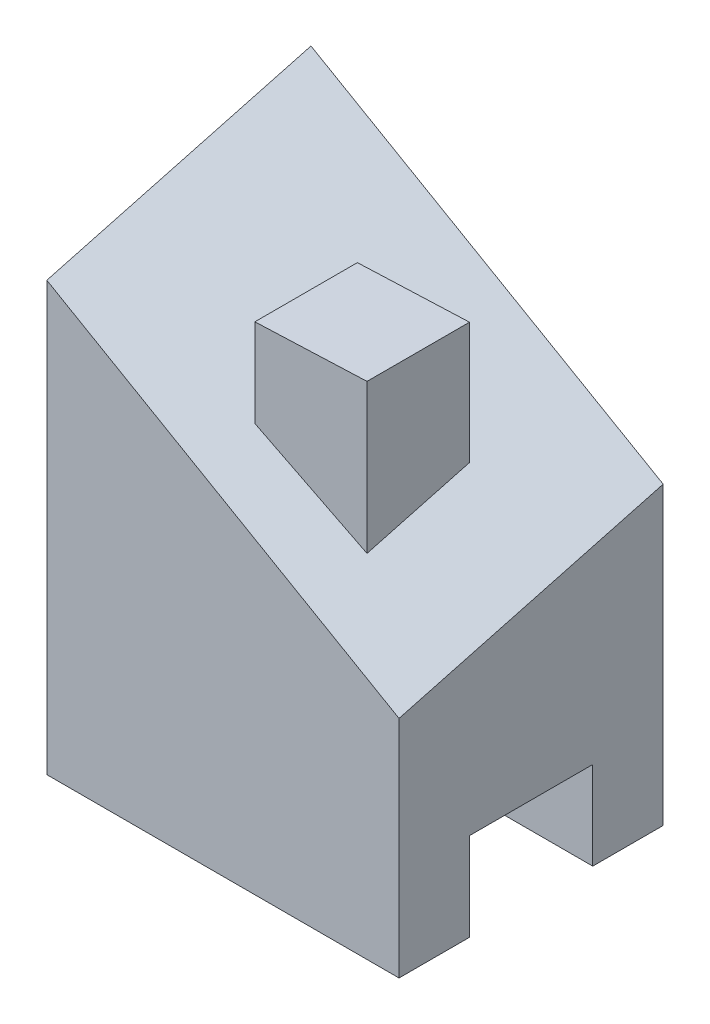
from build123d import *

# Parameters (mm, degrees)
SKETCH1_W                = 60
SKETCH1_H                = 45
BOSS_EXTRUDE1_DEPTH      = 85
SKETCH2_W                = 21
SKETCH2_H                = 15
CUT_EXTRUDE1_DEPTH       = 85
CUT_EXTRUDE7_DEPTH       = 53
CUT_EXTRUDE9_DEPTH       = 42
CUT_EXTRUDE10_DEPTH      = 42
BOSS_EXTRUDE6_DEPTH      = 15
BOSS_EXTRUDE6_DEPTH_BACK = 15


with BuildPart() as part:
    # Sketch1 → Boss-Extrude1 (new body)
    with BuildSketch(Plane(origin=(0, 0, 0), x_dir=(1, 0, 0), z_dir=(0, 1, 0))):
        with Locations((30, 22.5)):
            Rectangle(SKETCH1_W, SKETCH1_H)
    extrude(amount=BOSS_EXTRUDE1_DEPTH)

    # Sketch2 → Cut-Extrude1 (cut)
    with BuildSketch(Plane(origin=(60, 0, 0), x_dir=(0, 0, -1), z_dir=(1, 0, 0))):
        with Locations((22.5, 7.5)):
            Rectangle(SKETCH2_W, SKETCH2_H)
    extrude(amount=-CUT_EXTRUDE1_DEPTH, mode=Mode.SUBTRACT)

    # Sketch10 → Cut-Extrude7 (cut)
    with BuildSketch(Plane.XY):
        Polygon((0, 85), (60, 50.358983849), (60, 85), align=None)
    extrude(amount=-CUT_EXTRUDE7_DEPTH, mode=Mode.SUBTRACT)

    # Sketch16 → Cut-Extrude9 (cut)
    with BuildSketch(Plane.ZY):
        Polygon((-45, 85), (0, 72.942286341), (0, 85), align=None)
    extrude(amount=-CUT_EXTRUDE9_DEPTH, mode=Mode.SUBTRACT)

    # Sketch17 → Cut-Extrude10 (cut)
    with BuildSketch(Plane(origin=(29.971067136, 51.911411037, 13.909620665), x_dir=(0.8733693623277136, -0.47046235880286186, -0.12606000911046442), z_dir=(0.48705847384814394, 0.843610022961955, 0.22604462437945042))):
        Polygon((34.382855821, 56.500526295), (34.382855821, 9.913098177), (-34.316600088, 18.878852898), (-34.316600088, 65.466281017), align=None)
    extrude(amount=CUT_EXTRUDE10_DEPTH, mode=Mode.SUBTRACT)

    # Sketch38 → Boss-Extrude6 (add, two sides: drawn at the far end of the back side and taken through both)
    with BuildSketch(Plane(origin=(0, 60.290929389, 0), x_dir=(-1, 0, 0), z_dir=(0, -1, 0)).offset(-BOSS_EXTRUDE6_DEPTH_BACK)):
        Polygon((-26.20108087, 9.239976128), (-44.541837479, 10.004497867), (-44.541837479, 27.465894941), (-26.20108087, 26.701373203), align=None)
    extrude(amount=BOSS_EXTRUDE6_DEPTH + BOSS_EXTRUDE6_DEPTH_BACK)


solid = part.part
